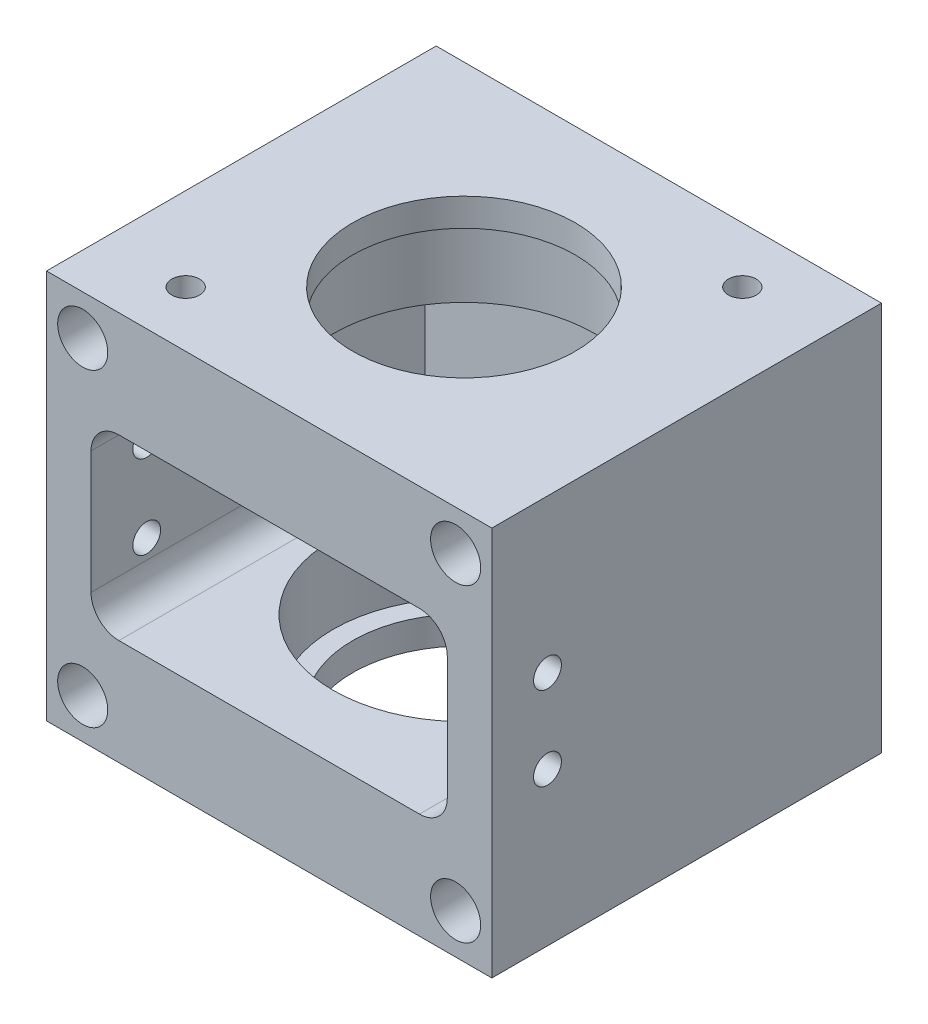
from build123d import *

# Parameters (mm, degrees)
SKETCH_1_W             = 80
SKETCH_1_H             = 70
EXTRUDE_1_DEPTH        = 70
SKETCH_2_W             = 64
SKETCH_2_H             = 32
CUT_EXTRUDE_1_DEPTH    = 60
SKETCH_3_R             = 4.5
CUT_EXTRUDE_5_DEPTH    = 100
SKETCH_6_R             = 5.5
CUT_EXTRUDE_7_DEPTH    = 30
SKETCH_5_R             = 20
CUT_EXTRUDE_8_DEPTH    = 87
SKETCH_7_R             = 23.5
CUT_EXTRUDE_9_DEPTH    = 14
FILLET_1_R             = 5
HOLE_WIZARD_M6_1_D     = 5
HOLE_WIZARD_M6_2_D     = 5
HOLE_WIZARD_M6_2_DEPTH = 10
HOLE_WIZARD_M6_2_TIP   = 1.502151548
HOLE_WIZARD_M6_3_D     = 5
HOLE_WIZARD_M6_3_DEPTH = 15
HOLE_WIZARD_M6_3_TIP   = 1.502151548


with BuildPart() as part:
    # 草图1 → 凸台-拉伸1 (new body)
    with BuildSketch(Plane.XY):
        Rectangle(SKETCH_1_W, SKETCH_1_H)
    extrude(amount=EXTRUDE_1_DEPTH)

    # 草图2 → 切除-拉伸1 (cut)
    with BuildSketch(Plane.XY.offset(70)):
        Rectangle(SKETCH_2_W, SKETCH_2_H)
    extrude(amount=-CUT_EXTRUDE_1_DEPTH, mode=Mode.SUBTRACT)

    # 草图3 → 切除-拉伸5 (cut)
    with BuildSketch(Plane.XY):
        with Locations((-33.5, 27.8)):
            Circle(SKETCH_3_R)
        with Locations((33.5, 27.8)):
            Circle(SKETCH_3_R)
        with Locations((33.5, -27.8)):
            Circle(SKETCH_3_R)
        with Locations((-33.5, -27.8)):
            Circle(SKETCH_3_R)
    extrude(amount=CUT_EXTRUDE_5_DEPTH, mode=Mode.SUBTRACT)

    # 草图6 → 切除-拉伸7 (cut)
    with BuildSketch(Plane(origin=(0, 0, 0), x_dir=(-1, 0, 0), z_dir=(0, 0, -1))):
        with Locations((-33.5, 27.8)):
            Circle(SKETCH_6_R)
        with Locations((33.5, 27.8)):
            Circle(SKETCH_6_R)
        with Locations((33.5, -27.8)):
            Circle(SKETCH_6_R)
        with Locations((-33.5, -27.8)):
            Circle(SKETCH_6_R)
    extrude(amount=-CUT_EXTRUDE_7_DEPTH, mode=Mode.SUBTRACT)

    # 草图5 → 切除-拉伸8 (cut)
    with BuildSketch(Plane(origin=(-5, 35, 0), x_dir=(0, 0, 1), z_dir=(0, -1, 0))):
        with Locations((35, -5)):
            Circle(SKETCH_5_R)
    extrude(amount=CUT_EXTRUDE_8_DEPTH, mode=Mode.SUBTRACT)

    # 草图7 → 切除-拉伸9 (cut)
    with BuildSketch(Plane.XZ.offset(-16)):
        with Locations((0, 35)):
            Circle(SKETCH_7_R)
    cut_extrude_9 = extrude(amount=-CUT_EXTRUDE_9_DEPTH, mode=Mode.SUBTRACT)

    # 镜向1: 切除-拉伸9 across plane
    add(cut_extrude_9.mirror(Plane(origin=(0, 0, 0), x_dir=(0, 0, 1), z_dir=(0, -1, 0))), mode=Mode.SUBTRACT)

    # 圆角1
    fillet_1_edges = [part.edges().sort_by_distance(p)[0] for p in [
        (32, 16, 40),
        (32, -16, 40),
        (-32, -16, 40),
        (-32, 16, 40),
    ]]
    fillet(fillet_1_edges, radius=FILLET_1_R)

    # M6 螺纹孔1 (through all)
    with Locations(Plane(origin=(-40, 7.5, 60), x_dir=(0, -1, 0), z_dir=(-1, 0, 0))):
        with Locations((0, 0), (15, 0)):
            Hole(HOLE_WIZARD_M6_1_D / 2)

    # M6 螺纹孔2
    with Locations(Plane(origin=(25, 35, 10), x_dir=(0, 0, 1), z_dir=(0, 1, 0))):
        with Locations((0, 0), (50, -50)):
            Hole(HOLE_WIZARD_M6_2_D / 2, depth=HOLE_WIZARD_M6_2_DEPTH)
            with Locations((0, 0, -(HOLE_WIZARD_M6_2_DEPTH + HOLE_WIZARD_M6_2_TIP / 2))):  # 118° drill point
                Cone(0, HOLE_WIZARD_M6_2_D / 2, HOLE_WIZARD_M6_2_TIP, mode=Mode.SUBTRACT)

    # M6 螺纹孔3
    with Locations(Plane(origin=(-25, -35, 60), x_dir=(0, 0, -1), z_dir=(0, -1, 0))):
        with Locations((0, 0), (0, 50), (50, 50), (50, 0)):
            Hole(HOLE_WIZARD_M6_3_D / 2, depth=HOLE_WIZARD_M6_3_DEPTH)
            with Locations((0, 0, -(HOLE_WIZARD_M6_3_DEPTH + HOLE_WIZARD_M6_3_TIP / 2))):  # 118° drill point
                Cone(0, HOLE_WIZARD_M6_3_D / 2, HOLE_WIZARD_M6_3_TIP, mode=Mode.SUBTRACT)


solid = part.part
